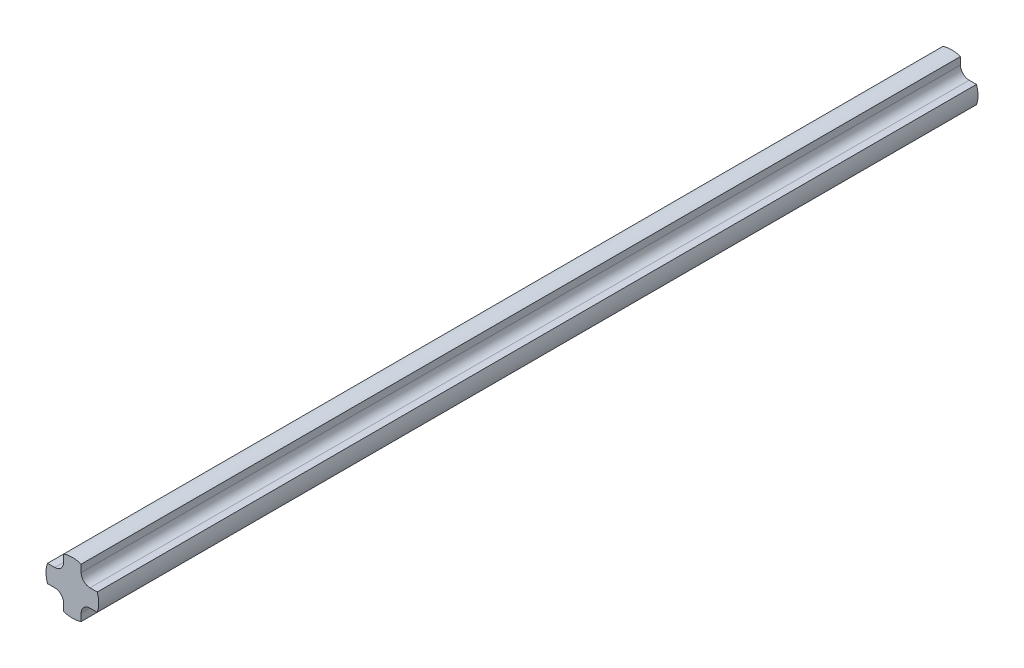
from build123d import *

# Parameters (mm, degrees)
BOSS_EXTRUDE1_DEPTH = 5000
CIRPATTERN1_COUNT   = 4
FILLET1_R           = 50


with BuildPart() as part:
    # Sketch1 → Boss-Extrude1 (new body)
    with BuildSketch(Plane(origin=(0, 0, 0), x_dir=(0, 1, 0), z_dir=(0, 0, 1))):
        with BuildLine():
            Line((-50, 141.421356237), (-50, 0))
            Line((-50, 0), (50, 0))
            Line((50, 0), (50, 141.421356237))
            ThreePointArc((50, 141.421356237), (0, 150), (-50, 141.421356237))
        make_face()
    extrude(amount=BOSS_EXTRUDE1_DEPTH)


with BuildPart() as cirpattern1_1:
    # CirPattern1: pattern copy
    add(part.part.rotate(Axis((0, 0, -10), (0, 0, 1)), 1 * 360 / CIRPATTERN1_COUNT))


with BuildPart() as cirpattern1_2:
    # CirPattern1: pattern copy
    add(part.part.rotate(Axis((0, 0, -10), (0, 0, 1)), 2 * 360 / CIRPATTERN1_COUNT))


with BuildPart() as cirpattern1_3:
    # CirPattern1: pattern copy
    add(part.part.rotate(Axis((0, 0, -10), (0, 0, 1)), 3 * 360 / CIRPATTERN1_COUNT))


with BuildPart() as part_1:
    add(part.part)

    # Combine1: union CirPattern1_1, CirPattern1_2, CirPattern1_3
    add(cirpattern1_1.part)
    add(cirpattern1_2.part)
    add(cirpattern1_3.part)

    # Fillet1
    fillet1_edges = [part_1.edges().sort_by_distance(p)[0] for p in [
        (50, 50, 2500),
        (50, -50, 2500),
        (-50, 50, 2500),
        (-50, -50, 2500),
    ]]
    fillet(fillet1_edges, radius=FILLET1_R)


solid = part_1.part
